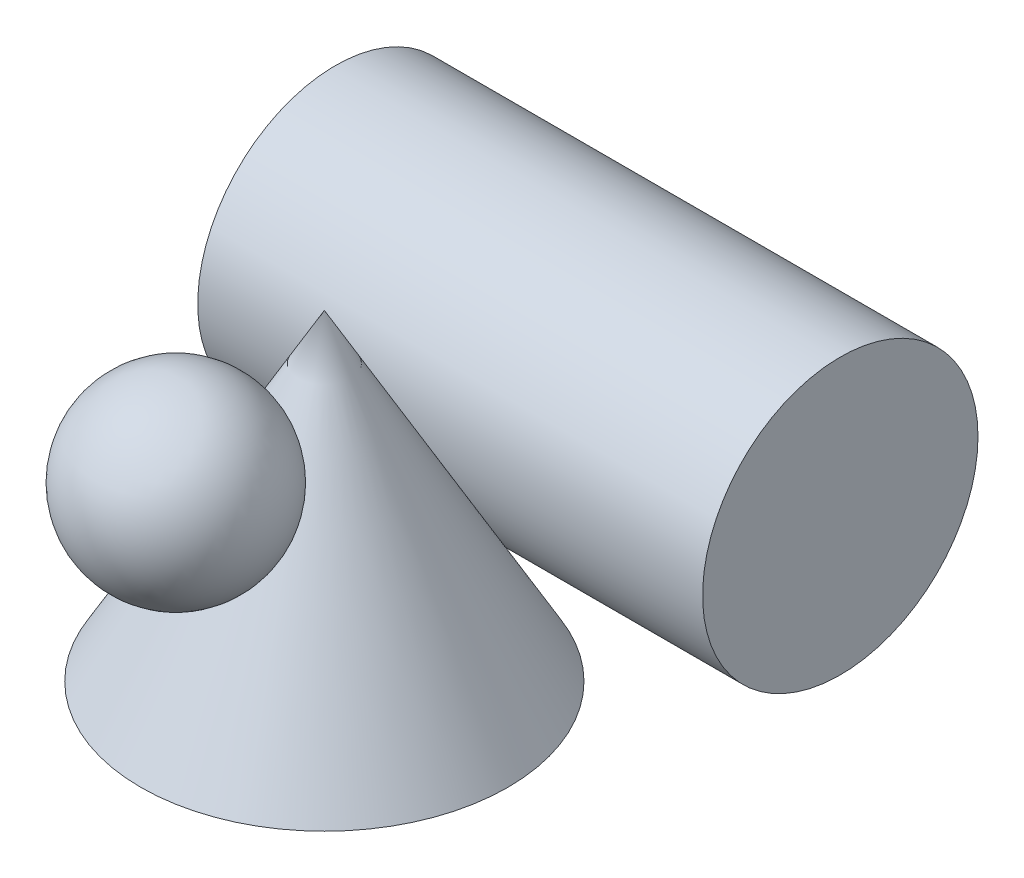
from build123d import *

# Parameters (mm, degrees)
SKETCH2_R      = 30
EXTRUDE1_DEPTH = 55


with BuildPart() as part:
    # Sketch1 → Revolve1 (revolve)
    with BuildSketch(Plane.XY):
        Polygon((0, 0), (40, 0), (0, 70), align=None)
    revolve(axis=Axis((0, 70, 0), (0, -1, 0)))


with BuildPart() as body_2:
    # Sketch2 → Extrude1 (new body, symmetric)
    with BuildSketch(Plane(origin=(0, 0, 0), x_dir=(0, 0, -1), z_dir=(1, 0, 0))):
        with Locations((57.409676064, 30)):
            Circle(SKETCH2_R)
    extrude(amount=EXTRUDE1_DEPTH, both=True)


with BuildPart() as body_3:
    # Sketch3 → Revolve2 (revolve)
    with BuildSketch(Plane(origin=(0, 0, 0), x_dir=(0, 0, -1), z_dir=(1, 0, 0))):
        with BuildLine():
            Line((-32.364862842, 73.672778767), (-32.364862842, 33.672778767))
            ThreePointArc((-32.364862842, 33.672778767), (-12.364862842, 53.672778767), (-32.364862842, 73.672778767))
        make_face()
    revolve(axis=Axis((0, 73.672778767, 32.364862842), (0, -1, 0)))


solid = Compound([part.part, body_2.part, body_3.part])
